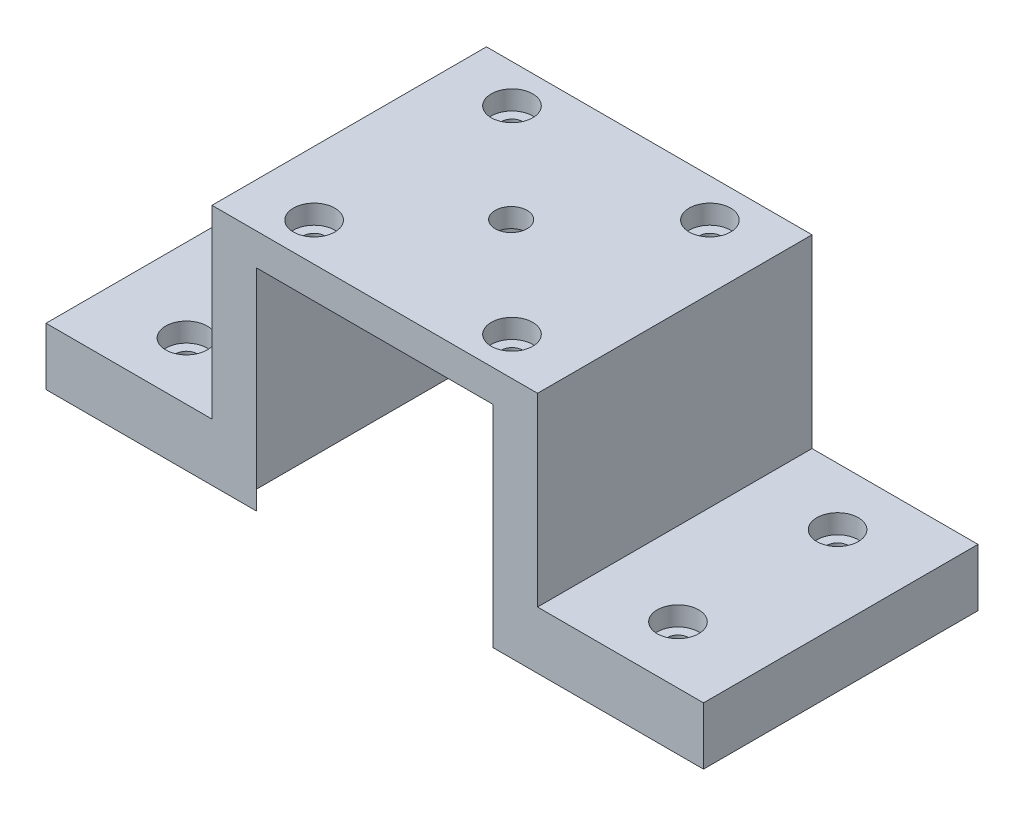
from build123d import *

# Parameters (mm, degrees)
BOSS_EXTRUDE1_DEPTH            = 43
BOSS_EXTRUDE2_DEPTH            = 33
SKETCH6_R                      = 11
CUT_EXTRUDE1_DEPTH             = 2
SKETCH7_R                      = 2.5
CUT_EXTRUDE2_DEPTH             = 4
CBORE_FOR_M3_SHCS1_D           = 3.4
CBORE_FOR_M3_SHCS1_CBORE_D     = 6.5
CBORE_FOR_M3_SHCS1_CBORE_DEPTH = 3
CBORE_FOR_M3_SHCS2_D           = 3.4
CBORE_FOR_M3_SHCS2_CBORE_D     = 6.5
CBORE_FOR_M3_SHCS2_CBORE_DEPTH = 3
CBORE_FOR_M3_SHCS3_D           = 3.4
CBORE_FOR_M3_SHCS3_CBORE_D     = 6.5
CBORE_FOR_M3_SHCS3_CBORE_DEPTH = 3


with BuildPart() as part:
    # Sketch1 → Boss-Extrude1 (new body)
    with BuildSketch(Plane.XY):
        Polygon((-51.369142857, 0), (-21.369142857, 0), (-21.369142857, 33), (21.630857143, 33), (21.630857143, 0), (51.630857143, 0), (51.630857143, 9), (25.630857143, 9), (25.630857143, 38), (-25.369142857, 38), (-25.369142857, 9), (-51.369142857, 9), align=None)
    extrude(amount=BOSS_EXTRUDE1_DEPTH)

    # Sketch5 → Boss-Extrude2 (add)
    with BuildSketch(Plane.XZ.offset(-33)):
        Polygon((-21.369142857, 43), (-18.369142857, 43), (-21.369142857, 40), align=None)
        Polygon((21.630857143, 40), (21.630857143, 43), (18.630857143, 43), align=None)
        Polygon((18.630857143, 0), (21.630857143, 0), (21.630857143, 3), align=None)
        Polygon((-18.369142857, 0), (-21.369142857, 0), (-21.369142857, 3), align=None)
    extrude(amount=BOSS_EXTRUDE2_DEPTH)

    # Sketch6 → Cut-Extrude1 (cut)
    with BuildSketch(Plane.XZ.offset(-33)):
        with Locations((0, 21.5)):
            Circle(SKETCH6_R)
    extrude(amount=-CUT_EXTRUDE1_DEPTH, mode=Mode.SUBTRACT)

    # Sketch7 → Cut-Extrude2 (cut, through all)
    with BuildSketch(Plane.XZ.offset(-35)):
        with Locations((0, 21.5)):
            Circle(SKETCH7_R)
    extrude(amount=-CUT_EXTRUDE2_DEPTH, mode=Mode.SUBTRACT)

    # CBORE for M3 SHCS1 (through all)
    with Locations(Plane(origin=(0, 38, 0), x_dir=(1, 0, 0), z_dir=(0, 1, 0))):
        with Locations((-15.369142857, -6), (-15.369142857, -37), (15.630857143, -37), (15.630857143, -6)):
            CounterBoreHole(CBORE_FOR_M3_SHCS1_D / 2, CBORE_FOR_M3_SHCS1_CBORE_D / 2, CBORE_FOR_M3_SHCS1_CBORE_DEPTH)

    # CBORE for M3 SHCS2 (through all)
    with Locations(Plane(origin=(0, 9, 0), x_dir=(1, 0, 0), z_dir=(0, 1, 0))):
        with Locations((-38.369142857, -9), (-38.369142857, -34)):
            CounterBoreHole(CBORE_FOR_M3_SHCS2_D / 2, CBORE_FOR_M3_SHCS2_CBORE_D / 2, CBORE_FOR_M3_SHCS2_CBORE_DEPTH)

    # CBORE for M3 SHCS3 (through all)
    with Locations(Plane(origin=(0, 9, 0), x_dir=(1, 0, 0), z_dir=(0, 1, 0))):
        with Locations((38.630857143, -34), (38.630857143, -9)):
            CounterBoreHole(CBORE_FOR_M3_SHCS3_D / 2, CBORE_FOR_M3_SHCS3_CBORE_D / 2, CBORE_FOR_M3_SHCS3_CBORE_DEPTH)


solid = part.part
